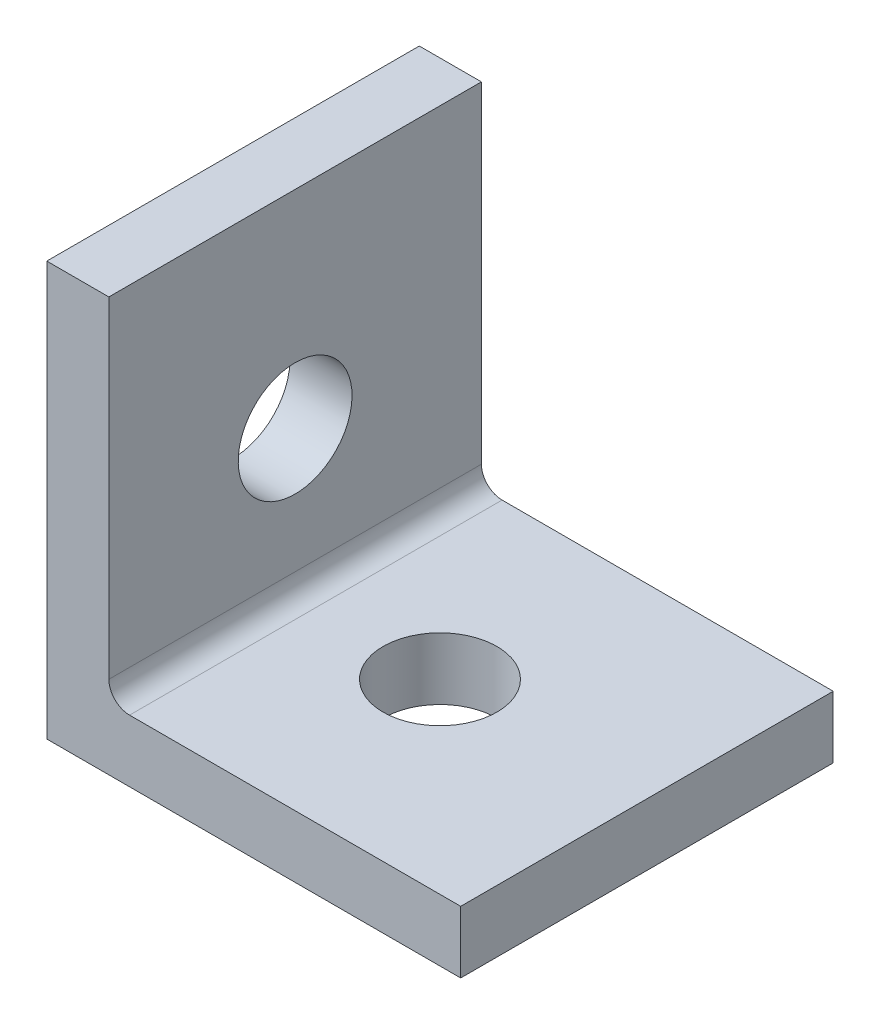
from build123d import *

# Parameters (mm, degrees)
BOSS_EXTRUDE1_DEPTH = 9
SKETCH2_R           = 2.75
CUT_EXTRUDE1_DEPTH  = 4
SKETCH3_R           = 2.75
CUT_EXTRUDE2_DEPTH  = 4


with BuildPart() as part:
    # Sketch1 → Boss-Extrude1 (new body, symmetric)
    with BuildSketch(Plane.XY):
        with BuildLine():
            Line((0, 0), (0, 20))
            Line((0, 20), (3, 20))
            Line((3, 20), (3, 4))
            ThreePointArc((3, 4), (3.292893219, 3.292893219), (4, 3))
            Line((4, 3), (20, 3))
            Line((20, 3), (20, 0))
            Line((20, 0), (0, 0))
        make_face()
    extrude(amount=BOSS_EXTRUDE1_DEPTH, both=True)

    # Sketch2 → Cut-Extrude1 (cut, through all)
    with BuildSketch(Plane(origin=(0, 3, 0), x_dir=(1, 0, 0), z_dir=(0, 1, 0))):
        with Locations((10, 0)):
            Circle(SKETCH2_R)
    extrude(amount=-CUT_EXTRUDE1_DEPTH, mode=Mode.SUBTRACT)

    # Sketch3 → Cut-Extrude2 (cut, through all)
    with BuildSketch(Plane(origin=(3, 0, 0), x_dir=(0, 0, -1), z_dir=(1, 0, 0))):
        with Locations((0, 10)):
            Circle(SKETCH3_R)
    extrude(amount=-CUT_EXTRUDE2_DEPTH, mode=Mode.SUBTRACT)


solid = part.part
